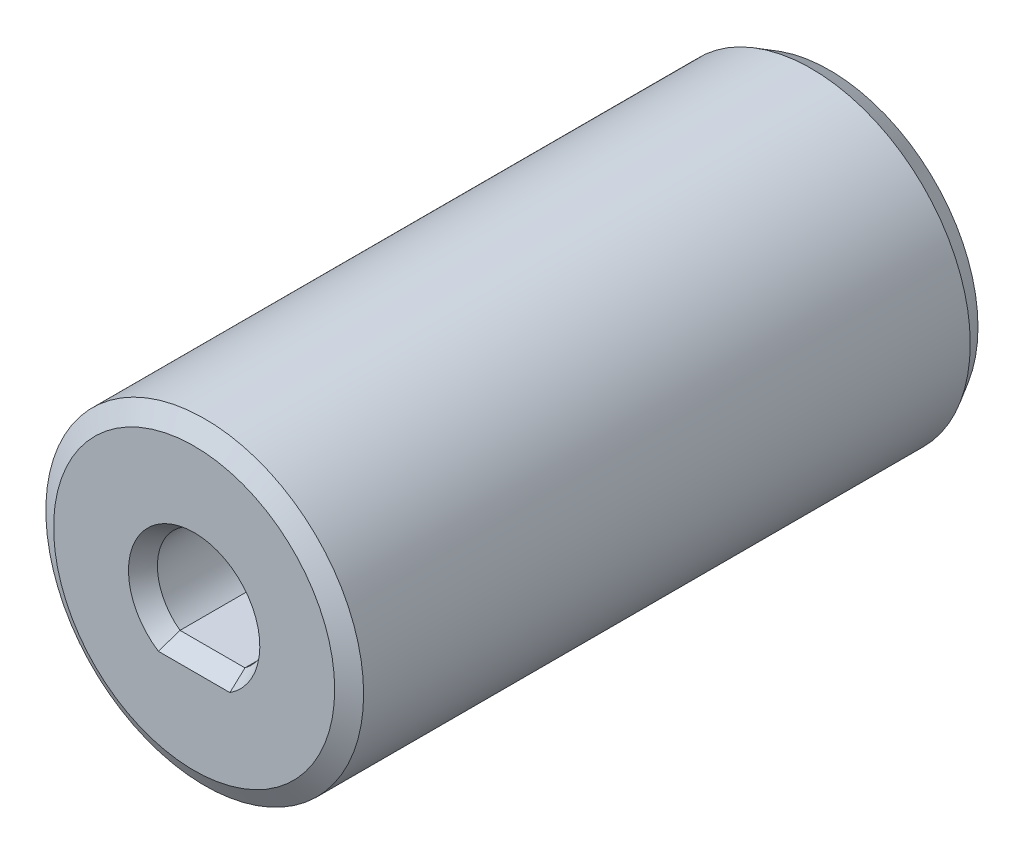
from build123d import *

# Parameters (mm, degrees)
OD_PROFILE_SKETCH_R                = 7.5
OD_BOSS_EXTRUDE_DEPTH              = 30
WHEEL_SHAFT_PROFILE_SKETCH_R       = 4.95
WHEEL_SHAFT_CUT_EXTRUDE_DEPTH      = 10
NEMA17_SHAFT_CUT_EXTRUDE_DEPTH     = 10
TAP_DRILL_FOR_M3X0_5_D             = 2.4
TAP_DRILL_FOR_M3X0_5_DEPTH         = 5.4
EDGE_CHAMFER_1MM_X_60_SIZE         = 0.5
EDGE_CHAMFER_1MM_X_60_SIZE2        = 0.866025404
EDGE_CHAMFER_1MM_X_60_PART_2_SIZE  = 0.5
EDGE_CHAMFER_1MM_X_60_PART_2_SIZE2 = 0.866025404
EDGE_CHAMFER_1MM_X_60_PART_3_SIZE  = 0.5
EDGE_CHAMFER_1MM_X_60_PART_3_SIZE2 = 0.866025404
EDGE_CHAMFER_1MM_X_60_PART_4_SIZE  = 0.5
EDGE_CHAMFER_1MM_X_60_PART_4_SIZE2 = 0.866025404
EDGE_CHAMFER_1MM_X_60_PART_5_SIZE  = 0.5
EDGE_CHAMFER_1MM_X_60_PART_5_SIZE2 = 0.866025404


with BuildPart() as part:
    # OD Profile Sketch → OD Boss-Extrude (new body)
    with BuildSketch(Plane.XY):
        Circle(OD_PROFILE_SKETCH_R)
    extrude(amount=OD_BOSS_EXTRUDE_DEPTH)

    # Wheel Shaft Profile Sketch → Wheel Shaft Cut-Extrude (cut)
    with BuildSketch(Plane.XY):
        Circle(WHEEL_SHAFT_PROFILE_SKETCH_R)
        with BuildLine():
            Line((1.967231557, -1.7), (-1.967231557, -1.7))
            ThreePointArc((-1.967231557, -1.7), (-2.6, 0), (-1.967231557, 1.7))
            Line((-1.967231557, 1.7), (1.967231557, 1.7))
            ThreePointArc((1.967231557, 1.7), (2.6, 0), (1.967231557, -1.7))
        make_face(mode=Mode.SUBTRACT)
    extrude(amount=WHEEL_SHAFT_CUT_EXTRUDE_DEPTH, mode=Mode.SUBTRACT)

    # NEMA17 Shaft Profile Sketch → NEMA17 Shaft Cut-Extrude (cut)
    with BuildSketch(Plane.XY.offset(30)):
        with BuildLine():
            Line((-1.532970972, -2.1), (1.532970972, -2.1))
            ThreePointArc((1.532970972, -2.1), (0, 2.6), (-1.532970972, -2.1))
        make_face()
    extrude(amount=-NEMA17_SHAFT_CUT_EXTRUDE_DEPTH, mode=Mode.SUBTRACT)

    # Tap Drill for M3x0.5
    with Locations(Plane(origin=(0, -7.5, 0), x_dir=(-1, 0, 0), z_dir=(0, -1, 0))):
        with Locations((0, -25), (0, -5)):
            Hole(TAP_DRILL_FOR_M3X0_5_D / 2, depth=TAP_DRILL_FOR_M3X0_5_DEPTH)

    # Edge Chamfer (1mm x 60)
    edge_chamfer_1mm_x_60_edges = [part.edges().sort_by_distance(p)[0] for p in [
        (-7.5, 0, 0),
    ]]
    edge_chamfer_1mm_x_60_side = [part.faces().sort_by_distance(p)[0] for p in [
        (-7.287867966, 0, 0),
    ]]
    chamfer(edge_chamfer_1mm_x_60_edges, length=EDGE_CHAMFER_1MM_X_60_SIZE, length2=EDGE_CHAMFER_1MM_X_60_SIZE2, reference=edge_chamfer_1mm_x_60_side[0])

    # Edge Chamfer (1mm x 60) part 2
    edge_chamfer_1mm_x_60_part_2_edges = [part.edges().sort_by_distance(p)[0] for p in [
        (0, 2.6, 30),
        (0, -2.1, 30),
    ]]
    edge_chamfer_1mm_x_60_part_2_side = [part.faces().sort_by_distance(p)[0] for p in [
        (-7.287867966, 0, 30),
    ]]
    chamfer(edge_chamfer_1mm_x_60_part_2_edges, length=EDGE_CHAMFER_1MM_X_60_PART_2_SIZE, length2=EDGE_CHAMFER_1MM_X_60_PART_2_SIZE2, reference=edge_chamfer_1mm_x_60_part_2_side[0])

    # Edge Chamfer (1mm x 60) part 3
    edge_chamfer_1mm_x_60_part_3_edges = [part.edges().sort_by_distance(p)[0] for p in [
        (-7.5, 0, 30),
    ]]
    edge_chamfer_1mm_x_60_part_3_side = [part.faces().sort_by_distance(p)[0] for p in [
        (-7.5, 0, 15),
    ]]
    chamfer(edge_chamfer_1mm_x_60_part_3_edges, length=EDGE_CHAMFER_1MM_X_60_PART_3_SIZE, length2=EDGE_CHAMFER_1MM_X_60_PART_3_SIZE2, reference=edge_chamfer_1mm_x_60_part_3_side[0])

    # Edge Chamfer (1mm x 60) part 4
    edge_chamfer_1mm_x_60_part_4_edges = [part.edges().sort_by_distance(p)[0] for p in [
        (2.6, 0, 0),
        (0, 1.7, 0),
        (-2.6, 0, 0),
        (0, -1.7, 0),
    ]]
    edge_chamfer_1mm_x_60_part_4_side = [part.faces().sort_by_distance(p)[0] for p in [
        (0, 0, 0),
    ]]
    chamfer(edge_chamfer_1mm_x_60_part_4_edges, length=EDGE_CHAMFER_1MM_X_60_PART_4_SIZE, length2=EDGE_CHAMFER_1MM_X_60_PART_4_SIZE2, reference=edge_chamfer_1mm_x_60_part_4_side[0])

    # Edge Chamfer (1mm x 60) part 5
    edge_chamfer_1mm_x_60_part_5_edges = [part.edges().sort_by_distance(p)[0] for p in [
        (-4.95, 0, 0),
    ]]
    edge_chamfer_1mm_x_60_part_5_side = [part.faces().sort_by_distance(p)[0] for p in [
        (-4.95, 0, 5),
    ]]
    chamfer(edge_chamfer_1mm_x_60_part_5_edges, length=EDGE_CHAMFER_1MM_X_60_PART_5_SIZE, length2=EDGE_CHAMFER_1MM_X_60_PART_5_SIZE2, reference=edge_chamfer_1mm_x_60_part_5_side[0])


solid = part.part
